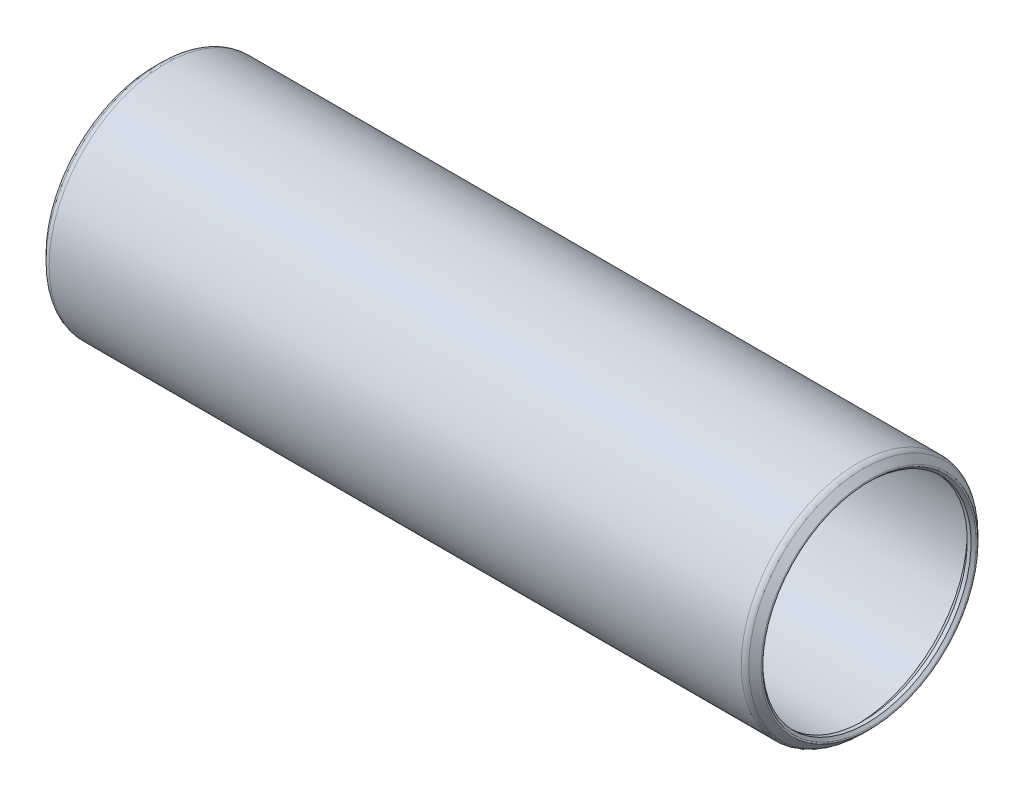
from build123d import *


with BuildPart() as part:
    # Sketch1 → Revolve1 (revolve)
    with BuildSketch(Plane.XY):
        with BuildLine():
            Line((-0.639512806, 10.742362806), (-0.381, 10.48385))
            Line((-0.381, 10.48385), (0, 10.48385))
            Line((0, 10.48385), (0.762, 11.24585))
            Line((0.762, 11.24585), (69.9389, 11.24585))
            Line((69.9389, 11.24585), (70.7009, 10.48385))
            Line((70.7009, 10.48385), (71.0819, 10.48385))
            Line((71.0819, 10.48385), (71.340412806, 10.742362806))
            ThreePointArc((71.340412806, 10.742362806), (71.377610245, 10.832165367), (71.340412806, 10.921967928))
            Line((71.340412806, 10.921967928), (70.725365367, 11.537015367))
            ThreePointArc((70.725365367, 11.537015367), (70.478154775, 11.702196204), (70.18655, 11.7602))
            Line((70.18655, 11.7602), (0.51435, 11.7602))
            ThreePointArc((0.51435, 11.7602), (0.222745225, 11.702196204), (-0.024465367, 11.537015367))
            Line((-0.024465367, 11.537015367), (-0.639512806, 10.921967928))
            ThreePointArc((-0.639512806, 10.921967928), (-0.676710245, 10.832165367), (-0.639512806, 10.742362806))
        make_face()
    revolve(axis=Axis((70.7009, 0, 0), (-1, 0, 0)))


solid = part.part
